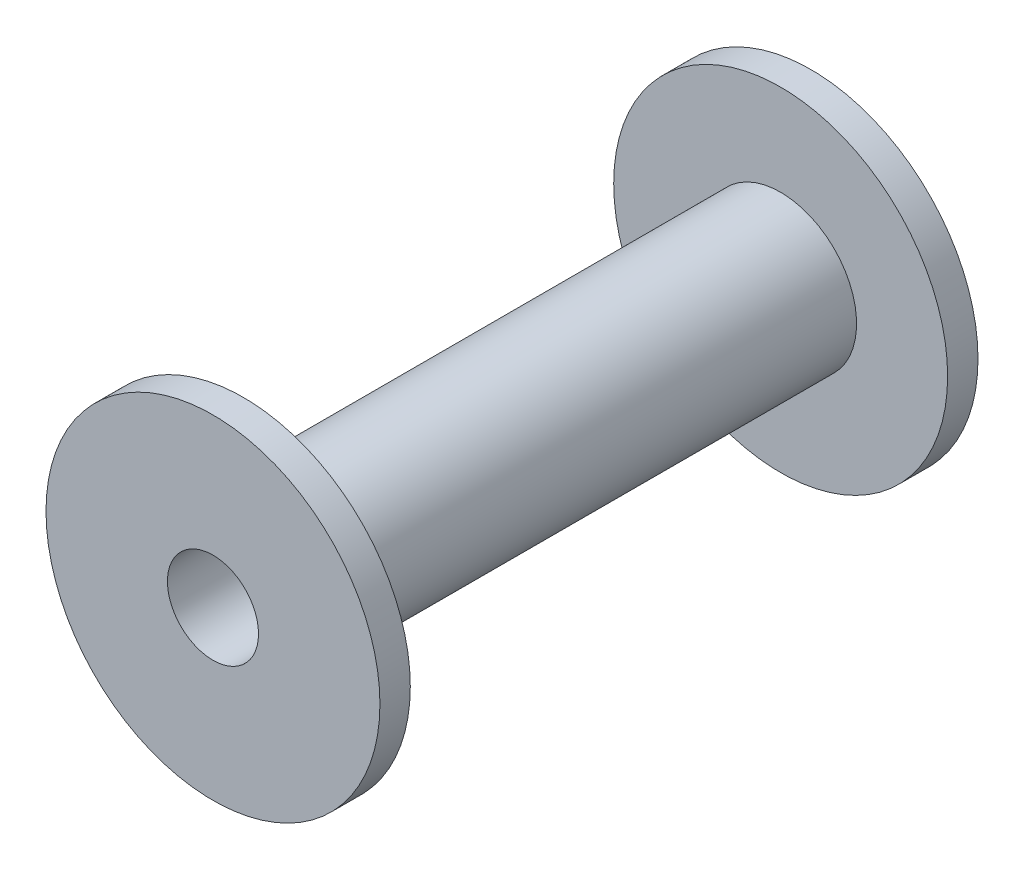
from build123d import *

# Parameters (mm, degrees)
ESQUISSE1_R        = 2.5
ESQUISSE1_R_2      = 1.5
BOSS_EXTRU_1_DEPTH = 9.85
ESQUISSE2_R        = 5.5
ESQUISSE2_R_2      = 2.5
BOSS_EXTRU_2_DEPTH = 1


with BuildPart() as part:
    # Esquisse1 → Boss.-Extru.1 (new body)
    with BuildSketch(Plane.XY):
        Circle(ESQUISSE1_R)
        Circle(ESQUISSE1_R_2, mode=Mode.SUBTRACT)
    boss_extru_1 = extrude(amount=BOSS_EXTRU_1_DEPTH)

    # Esquisse2 → Boss.-Extru.2 (add)
    with BuildSketch(Plane.XY.offset(9.85)):
        Circle(ESQUISSE2_R)
        Circle(ESQUISSE2_R_2, mode=Mode.SUBTRACT)
    boss_extru_2 = extrude(amount=-BOSS_EXTRU_2_DEPTH)

    # Symétrie1: Boss.-Extru.1, Boss.-Extru.2 across plane
    add(boss_extru_1.mirror(Plane.XY))
    add(boss_extru_2.mirror(Plane.XY))


solid = part.part
